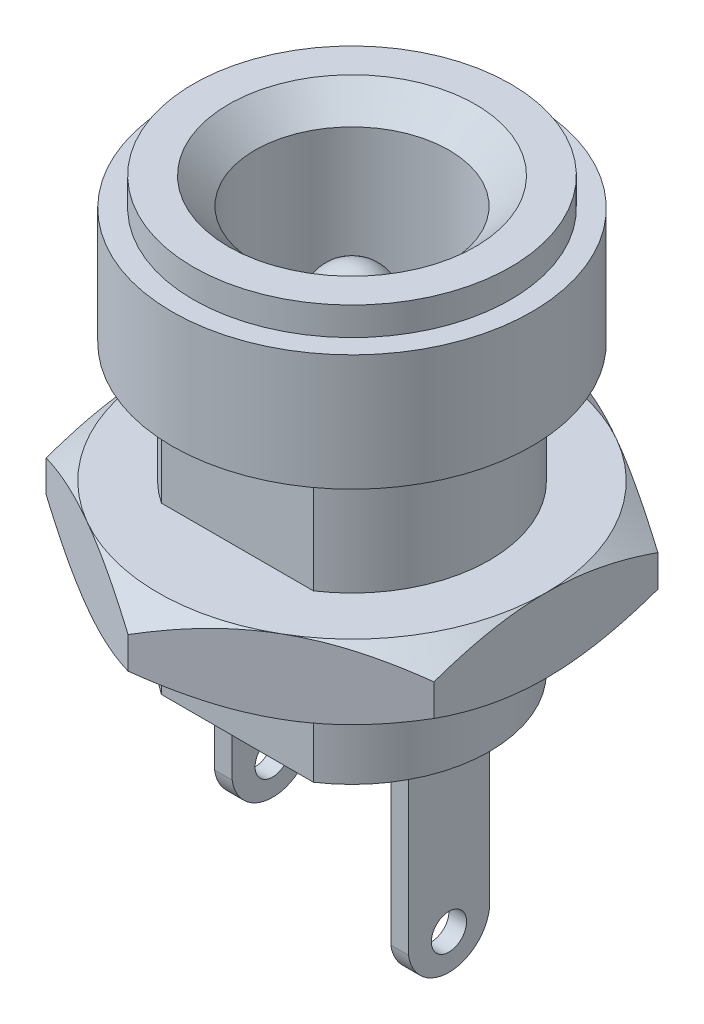
from build123d import *

# Parameters (mm, degrees)
SKETCH2_W           = 0.5
SKETCH2_H           = 2.3
BOSS_EXTRUDE1_DEPTH = 6
CUT_EXTRUDE1_REACH  = 9.85
SKETCH3_W           = 2.3
SKETCH3_H           = 1.8
CUT_EXTRUDE2_START  = -0.5
SKETCH4_R           = 0.5
CUT_EXTRUDE2_DEPTH  = 0.5
CUT_EXTRUDE3_START  = -0.5
SKETCH5_R           = 0.5
CUT_EXTRUDE3_DEPTH  = 0.5
SKETCH6_W           = 10
SKETCH6_H           = 10
CUT_EXTRUDE4_DEPTH  = 8.1
BOSS_EXTRUDE2_DEPTH = 2.1


with BuildPart() as part:
    # Sketch1 → Revolve1 (revolve)
    with BuildSketch(Plane.XY):
        with BuildLine():
            Line((3.9, 0), (3.9, 8.1))
            Line((3.9, 8.1), (5.1, 8.1))
            Line((5.1, 8.1), (5.1, 11.4))
            Line((5.1, 11.4), (4.5, 11.4))
            Line((4.5, 11.4), (4.5, 12.2))
            Line((4.5, 12.2), (3.5, 12.2))
            Line((3.5, 12.2), (2.75, 11.45))
            Line((2.75, 11.45), (2.75, 3.2))
            Line((2.75, 3.2), (1.05, 3.2))
            Line((1.05, 3.2), (1.05, 8.95))
            ThreePointArc((1.05, 8.95), (0.74246212, 9.69246212), (0, 10))
            Line((0, 10), (0, 2))
            Line((0, 2), (1.3, 2))
            Line((1.3, 2), (1.3, 0))
            Line((1.3, 0), (3.9, 0))
        make_face()
    revolve(axis=Axis((0, 10, 0), (0, -1, 0)))

    # Sketch2 → Boss-Extrude1 (add)
    with BuildSketch(Plane.XZ):
        with Locations((2.5, 0)):
            Rectangle(SKETCH2_W, SKETCH2_H)
        with Locations((-2.5, 0)):
            Rectangle(SKETCH2_W, SKETCH2_H)
    extrude(amount=BOSS_EXTRUDE1_DEPTH)

    # Sketch3 → Cut-Extrude1 (cut, up to next)
    with BuildSketch(Plane.ZY.offset(2.75), mode=Mode.PRIVATE) as cut_extrude1_sk1:
        with Locations((0, -5.1)):
            Rectangle(SKETCH3_W, SKETCH3_H)
    cut_extrude1_tool1 = extrude(cut_extrude1_sk1.sketch, amount=-CUT_EXTRUDE1_REACH, mode=Mode.PRIVATE) & part.part
    add(cut_extrude1_tool1.solids().sort_by_distance((-2.75, -5.1, 0))[0], mode=Mode.SUBTRACT)

    # Sketch4 → Cut-Extrude2 (cut)
    with BuildSketch(Plane.ZY.offset(2.75).offset(CUT_EXTRUDE2_START)):
        with Locations((0, -3.2)):
            Circle(SKETCH4_R)
        with BuildLine():
            Line((-1.15, -3.2), (-1.15, -4.4))
            Line((-1.15, -4.4), (1.15, -4.4))
            Line((1.15, -4.4), (1.15, -3.2))
            ThreePointArc((1.15, -3.2), (0, -4.2), (-1.15, -3.2))
        make_face()
    extrude(amount=CUT_EXTRUDE2_DEPTH, mode=Mode.SUBTRACT)

    # Sketch5 → Cut-Extrude3 (cut)
    with BuildSketch(Plane.ZY.offset(-2.25).offset(CUT_EXTRUDE3_START)):
        with Locations((0, -5)):
            Circle(SKETCH5_R)
        with BuildLine():
            Line((-1.15, -5), (-1.15, -6.5))
            Line((-1.15, -6.5), (1.15, -6.5))
            Line((1.15, -6.5), (1.15, -5))
            ThreePointArc((1.15, -5), (0, -6), (-1.15, -5))
        make_face()
    extrude(amount=CUT_EXTRUDE3_DEPTH, mode=Mode.SUBTRACT)

    # Sketch6 → Cut-Extrude4 (cut)
    with BuildSketch(Plane.XZ):
        with Locations((0, 8.25)):
            Rectangle(SKETCH6_W, SKETCH6_H)
        with Locations((0, -8.25)):
            Rectangle(SKETCH6_W, SKETCH6_H)
    extrude(amount=-CUT_EXTRUDE4_DEPTH, mode=Mode.SUBTRACT)

    # Sketch7 → Boss-Extrude2 (add)
    with BuildSketch(Plane(origin=(0, 4.7, 0), x_dir=(-1, 0, 0), z_dir=(0, -1, 0))):
        Polygon((0, 6.350852961), (-5.5, 3.175426481), (-5.5, -3.175426481), (0, -6.350852961), (5.5, -3.175426481), (5.5, 3.175426481), align=None)
    extrude(amount=BOSS_EXTRUDE2_DEPTH)

    # Sketch9 → Cut-Revolve1 (revolve, cut)
    with BuildSketch(Plane(origin=(0, 0, 0), x_dir=(0, 0, -1), z_dir=(1, 0, 0))):
        Polygon((6.350852961, 4.1), (5.5, 4.7), (8.5, 4.7), (8.5, 2.6), (5.5, 2.6), (6.350852961, 3.2), align=None)
    revolve(axis=Axis((0, 0, 0), (0, 1, 0)), mode=Mode.SUBTRACT)


solid = part.part
